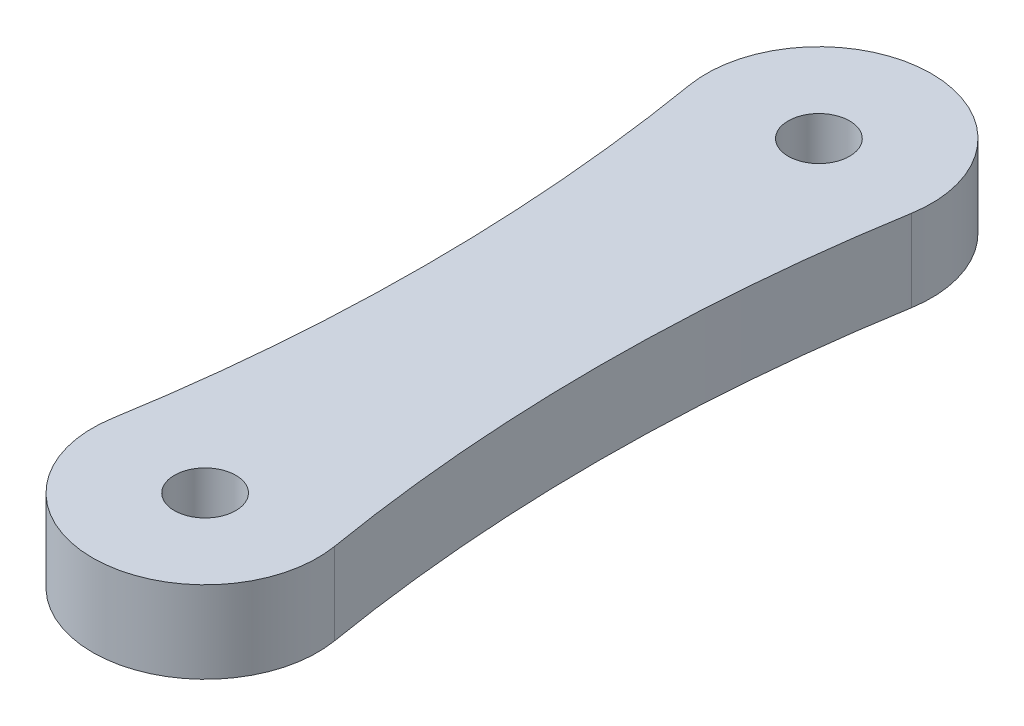
from build123d import *

# Parameters (mm, degrees)
SKETCH1_R           = 1.5
BOSS_EXTRUDE1_DEPTH = 4


with BuildPart() as part:
    # Sketch1 → Boss-Extrude1 (new body)
    with BuildSketch(Plane(origin=(0, 0, 0), x_dir=(1, 0, 0), z_dir=(0, 1, 0))):
        with BuildLine():
            ThreePointArc((-5.424137931, 0.910344828), (0, -5.5), (5.424137931, 0.910344828))
            ThreePointArc((5.424137931, 0.910344828), (4.25, 15), (5.424137931, 29.089655172))
            ThreePointArc((5.424137931, 29.089655172), (0, 35.5), (-5.424137931, 29.089655172))
            ThreePointArc((-5.424137931, 29.089655172), (-4.25, 15), (-5.424137931, 0.910344828))
        make_face()
        Circle(SKETCH1_R, mode=Mode.SUBTRACT)
        with Locations((0, 30)):
            Circle(SKETCH1_R, mode=Mode.SUBTRACT)
    extrude(amount=BOSS_EXTRUDE1_DEPTH)


solid = part.part
